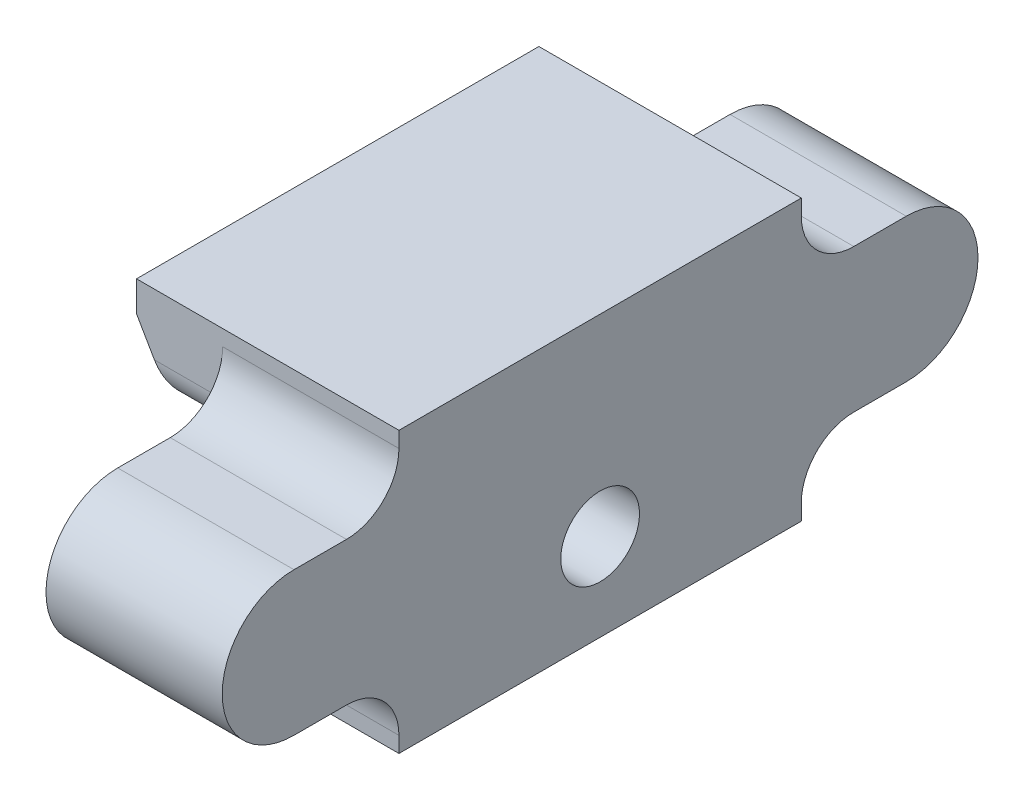
from build123d import *

# Parameters (mm, degrees)
EXTRUDE_1_DEPTH          = 23
SKETCH_2_R               = 2.5
CUT_EXTRUDE_1_DEPTH      = 4
CUT_EXTRUDE_1_DEPTH_BACK = 30.774100013
HOLE_WIZARD_M41_D        = 4.5
CHAMFER_1_SIZE           = 1
CHAMFER_1_SIZE2          = 2
EXTRUDE_2_DEPTH          = 10.074573519
FILLET_1_R               = 3
FILLET_2_R               = 2


with BuildPart() as part:
    # Эскиз1 → Бобышка-Вытянуть1 (new body)
    with BuildSketch(Plane.XY):
        Polygon((0, 0), (-10.074573519, 0), (-10.074573519, 10.5), (-12.824573519, 10.5), (-16, 16), (0, 16), align=None)
    extrude(amount=EXTRUDE_1_DEPTH)

    # Эскиз2 → Вырез-Вытянуть1 (cut, two sides)
    with BuildSketch(Plane(origin=(-10.074573519, 0, 0), x_dir=(0, 0, -1), z_dir=(1, 0, 0))) as cut_extrude_1_sk:
        with Locations((-19, 5)):
            Circle(SKETCH_2_R)
        with Locations(Location((-4, 5, 0), (0, 0, 90))):
            Circle(SKETCH_2_R)
    extrude(amount=CUT_EXTRUDE_1_DEPTH, mode=Mode.SUBTRACT)
    extrude(cut_extrude_1_sk.sketch, amount=-CUT_EXTRUDE_1_DEPTH_BACK, mode=Mode.SUBTRACT)

    # Отверстие с зазором M41 (through all)
    with Locations(Plane(origin=(0, 1.542761086, 4.525415006), x_dir=(0, 0, 1), z_dir=(1, 0, 0))):
        with Locations((6.974584994, -3.457238914)):
            Hole(HOLE_WIZARD_M41_D / 2)

    # Фаска1
    chamfer_1_edges = [part.edges().sort_by_distance(p)[0] for p in [
        (-16, 16, 11.5),
    ]]
    chamfer_1_side = [part.faces().sort_by_distance(p)[0] for p in [
        (-8, 16, 11.5),
    ]]
    chamfer(chamfer_1_edges, length=CHAMFER_1_SIZE, length2=CHAMFER_1_SIZE2, reference=chamfer_1_side[0])

    # Эскиз7 → Бобышка-Вытянуть2 (add)
    with BuildSketch(Plane.ZY):
        with BuildLine():
            Line((-6, 12.1), (0, 12.1))
            Line((0, 12.1), (0, 3.9))
            Line((0, 3.9), (-6, 3.9))
            ThreePointArc((-6, 3.9), (-10.1, 8), (-6, 12.1))
        make_face()
        with BuildLine():
            Line((23, 12.1), (23, 3.9))
            Line((23, 3.9), (29, 3.9))
            ThreePointArc((29, 3.9), (33.1, 8), (29, 12.1))
            Line((29, 12.1), (23, 12.1))
        make_face()
    extrude(amount=EXTRUDE_2_DEPTH)

    # Скругление1
    fillet_1_edges = [part.edges().sort_by_distance(p)[0] for p in [
        (-5.037286759, 3.9, 23),
        (-5.03728676, 12.1, 23),
        (-5.03728676, 12.1, 0),
        (-5.037286759, 3.9, 0),
    ]]
    fillet(fillet_1_edges, radius=FILLET_1_R)

    # Скругление2
    fillet_2_edges = [part.edges().sort_by_distance(p)[0] for p in [
        (-11.449573519, 10.5, 23),
        (-11.449573519, 10.5, 0),
    ]]
    fillet(fillet_2_edges, radius=FILLET_2_R)


solid = part.part
